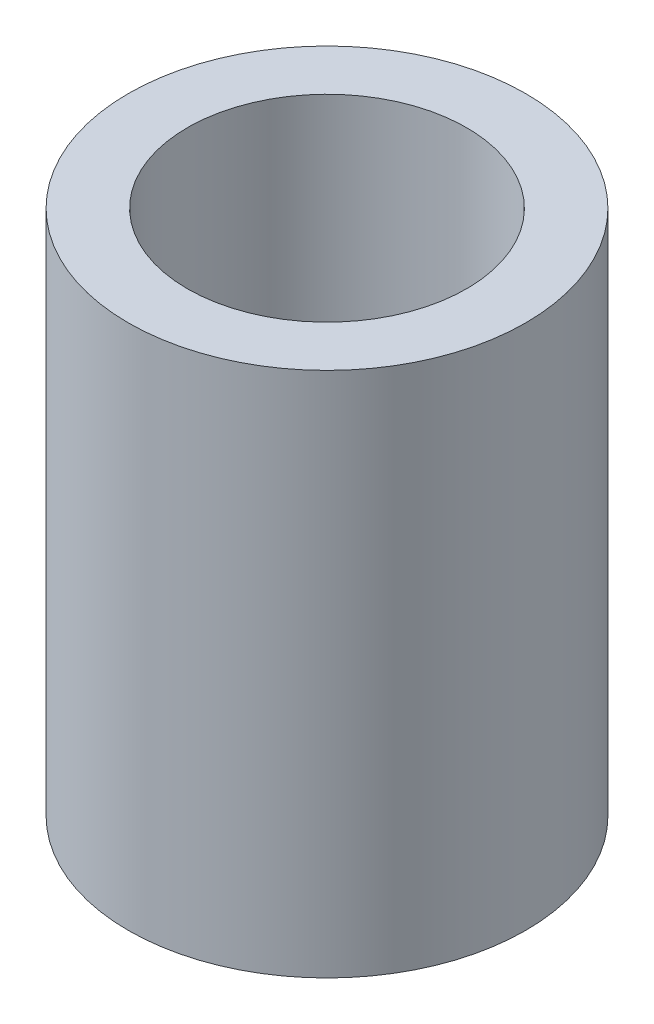
from build123d import *

# Parameters (mm, degrees)
SKETCH1_R           = 4.699
SKETCH1_R_2         = 3.302
BOSS_EXTRUDE1_DEPTH = 12.446


with BuildPart() as part:
    # Sketch1 → Boss-Extrude1 (new body)
    with BuildSketch(Plane(origin=(0, 0, 0), x_dir=(1, 0, 0), z_dir=(0, 1, 0))):
        Circle(SKETCH1_R)
        Circle(SKETCH1_R_2, mode=Mode.SUBTRACT)
    extrude(amount=BOSS_EXTRUDE1_DEPTH)


solid = part.part
